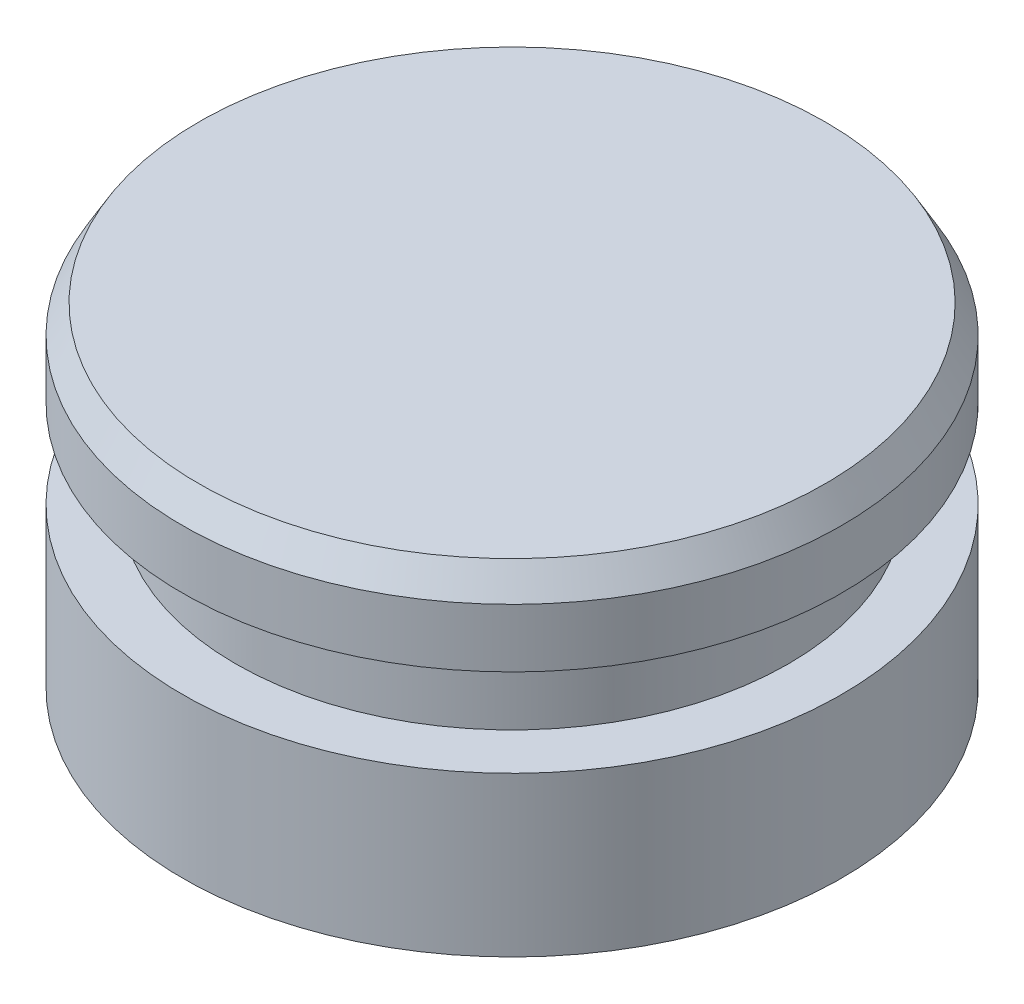
from build123d import *

# Parameters (mm, degrees)
CHAMFER1_SIZE  = 0.47037037
CHAMFER1_SIZE2 = 0.81470538


with BuildPart() as part:
    # Sketch1 → Revolve1 (revolve)
    with BuildSketch(Plane.XY):
        Polygon((0, 0), (-9.5377, 0), (-9.5377, 4.60375), (-8.001, 4.60375), (-8.001, 7.14375), (-9.5377, 7.14375), (-9.5377, 9.652), (0, 9.652), align=None)
    revolve(axis=Axis((0, 0, 0), (0, 1, 0)))

    # Chamfer1
    chamfer1_edges = [part.edges().sort_by_distance(p)[0] for p in [
        (9.5377, 9.652, 0),
    ]]
    chamfer1_side = [part.faces().sort_by_distance(p)[0] for p in [
        (0, 9.652, 0),
    ]]
    chamfer(chamfer1_edges, length=CHAMFER1_SIZE, length2=CHAMFER1_SIZE2, reference=chamfer1_side[0])


solid = part.part
